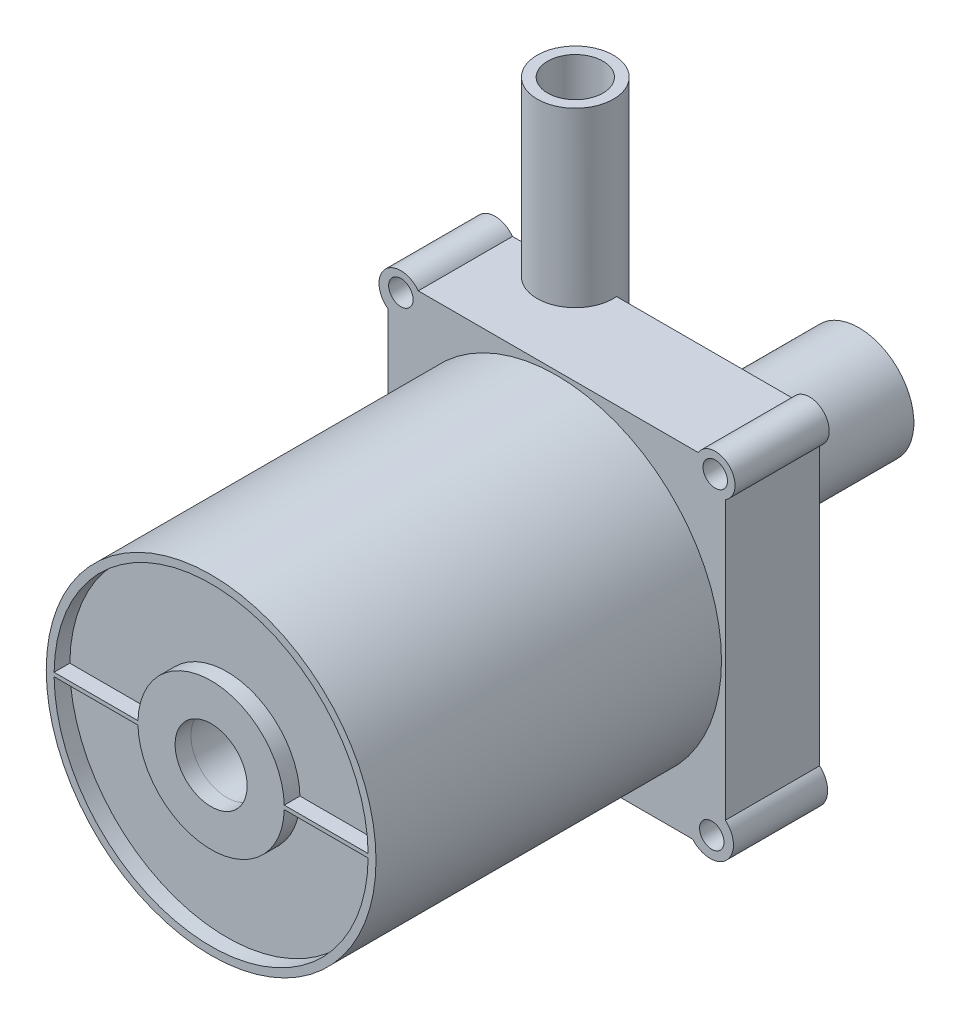
from build123d import *

# Parameters (mm, degrees)
SKETCH2_R                 = 21
BOSS_EXTRUDE4_DEPTH       = 44
SKETCH6_R                 = 2.52099285
SKETCH6_R_2               = 2.774223213
SKETCH6_R_3               = 2.958692603
SKETCH6_R_4               = 3.108326591
SKETCH6_W                 = 43
SKETCH6_H                 = 43
BOSS_EXTRUDE8_DEPTH       = 12
SKETCH7_R                 = 1.557999949
CUT_EXTRUDE1_DEPTH        = 12
SKETCH9_R                 = 14.25
BOSS_EXTRUDE10_DEPTH      = 4.5
SKETCH10_R                = 4.856031572
BOSS_EXTRUDE12_DEPTH      = 22
BOSS_EXTRUDE12_DEPTH_BACK = 22
SKETCH11_R                = 9
BOSS_EXTRUDE13_DEPTH      = 6
SKETCH12_R                = 7
BOSS_EXTRUDE14_DEPTH      = 16
SKETCH13_R                = 4.670506922
CUT_EXTRUDE3_DEPTH        = 120
SKETCH15_R                = 3.527063208
CUT_EXTRUDE5_DEPTH        = 40
SKETCH16_R                = 20
CUT_EXTRUDE6_DEPTH        = 2
SKETCH17_W                = 40.997064224
SKETCH17_H                = 0.490637438
BOSS_EXTRUDE15_DEPTH      = 2
SKETCH18_R                = 9.319375459
BOSS_EXTRUDE16_DEPTH      = 2
SKETCH19_R                = 4.582310756
CUT_EXTRUDE7_DEPTH        = 2


with BuildPart() as part:
    # Sketch2 → Boss-Extrude4 (new body)
    with BuildSketch(Plane.XY):
        Circle(SKETCH2_R)
    extrude(amount=BOSS_EXTRUDE4_DEPTH)

    # Sketch6 → Boss-Extrude8 (add)
    with BuildSketch(Plane(origin=(0, 0, 0), x_dir=(-1, 0, 0), z_dir=(0, 0, -1))):
        with Locations((-20.202035706, 20.202035706)):
            Circle(SKETCH6_R)
        with Locations((19.846366063, 19.846366063)):
            Circle(SKETCH6_R_2)
        with Locations((-19.561830349, -19.561830349)):
            Circle(SKETCH6_R_3)
        with Locations((19.846366063, -19.846366063)):
            Circle(SKETCH6_R_4)
        Rectangle(SKETCH6_W, SKETCH6_H)
    extrude(amount=BOSS_EXTRUDE8_DEPTH)

    # Sketch7 → Cut-Extrude1 (cut)
    with BuildSketch(Plane(origin=(0, 0, -12), x_dir=(-1, 0, 0), z_dir=(0, 0, -1))):
        with Locations((-20.202035706, 20.202035706)):
            Circle(SKETCH7_R)
        with Locations((19.832590029, 20.202035706)):
            Circle(SKETCH7_R)
        with Locations((19.846366063, -19.846366063)):
            Circle(SKETCH7_R)
        with Locations((-19.76209834, -19.846366063)):
            Circle(SKETCH7_R)
    extrude(amount=-CUT_EXTRUDE1_DEPTH, mode=Mode.SUBTRACT)

    # Sketch9 → Boss-Extrude10 (add)
    with BuildSketch(Plane(origin=(0, 0, -12), x_dir=(-1, 0, 0), z_dir=(0, 0, -1))):
        Circle(SKETCH9_R)
    extrude(amount=BOSS_EXTRUDE10_DEPTH)

    # Sketch10 → Boss-Extrude12 (add, two sides)
    with BuildSketch(Plane(origin=(0, 21.5, 0), x_dir=(1, 0, 0), z_dir=(0, 1, 0))) as boss_extrude12_sk:
        with Locations((-9.192655729, 11.573586892)):
            Circle(SKETCH10_R)
    extrude(amount=BOSS_EXTRUDE12_DEPTH)
    extrude(boss_extrude12_sk.sketch, amount=-BOSS_EXTRUDE12_DEPTH_BACK)

    # Sketch11 → Boss-Extrude13 (add)
    with BuildSketch(Plane(origin=(0, 0, -16.5), x_dir=(-1, 0, 0), z_dir=(0, 0, -1))):
        Circle(SKETCH11_R)
    extrude(amount=BOSS_EXTRUDE13_DEPTH)

    # Sketch12 → Boss-Extrude14 (add)
    with BuildSketch(Plane(origin=(0, 0, -22.5), x_dir=(-1, 0, 0), z_dir=(0, 0, -1))):
        Circle(SKETCH12_R)
    extrude(amount=BOSS_EXTRUDE14_DEPTH)

    # Sketch13 → Cut-Extrude3 (cut)
    with BuildSketch(Plane(origin=(0, 0, -38.5), x_dir=(-1, 0, 0), z_dir=(0, 0, -1))):
        Circle(SKETCH13_R)
    extrude(amount=-CUT_EXTRUDE3_DEPTH, mode=Mode.SUBTRACT)

    # Sketch15 → Cut-Extrude5 (cut)
    with BuildSketch(Plane(origin=(0, 43.5, 0), x_dir=(1, 0, 0), z_dir=(0, 1, 0))):
        with Locations((-9.192655729, 11.573586892)):
            Circle(SKETCH15_R)
    extrude(amount=-CUT_EXTRUDE5_DEPTH, mode=Mode.SUBTRACT)

    # Sketch16 → Cut-Extrude6 (cut)
    with BuildSketch(Plane.XY.offset(44)):
        Circle(SKETCH16_R)
    extrude(amount=-CUT_EXTRUDE6_DEPTH, mode=Mode.SUBTRACT)

    # Sketch17 → Boss-Extrude15 (add)
    with BuildSketch(Plane.XY.offset(42)):
        Rectangle(SKETCH17_W, SKETCH17_H)
    extrude(amount=BOSS_EXTRUDE15_DEPTH)

    # Sketch18 → Boss-Extrude16 (add)
    with BuildSketch(Plane.XY.offset(42)):
        Circle(SKETCH18_R)
    extrude(amount=BOSS_EXTRUDE16_DEPTH)

    # Sketch19 → Cut-Extrude7 (cut)
    with BuildSketch(Plane.XY.offset(44)):
        Circle(SKETCH19_R)
    extrude(amount=-CUT_EXTRUDE7_DEPTH, mode=Mode.SUBTRACT)


solid = part.part
